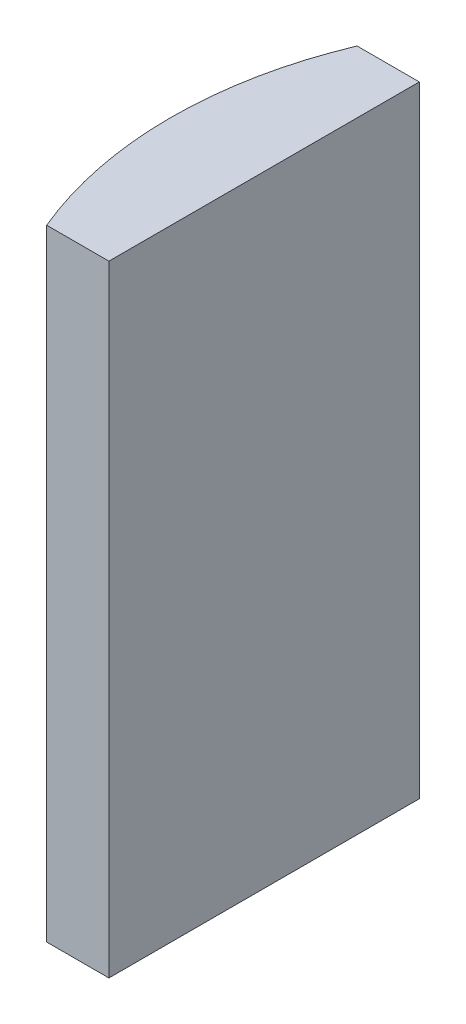
from build123d import *

# Parameters (mm, degrees)
EXTRUDE_1_DEPTH = 20


with BuildPart() as part:
    # 草图1 → 凸台-拉伸1 (new body)
    with BuildSketch(Plane(origin=(0, 0, 0), x_dir=(1, 0, 0), z_dir=(0, 1, 0))):
        with BuildLine():
            Line((-7.568926661, 5), (-5.564795665, 5))
            Line((-5.564795665, 5), (-5.564795665, -5))
            Line((-5.564795665, -5), (-7.568926661, -5))
            ThreePointArc((-7.568926661, -5), (-8.574795665, 0), (-7.568926661, 5))
        make_face()
    extrude(amount=EXTRUDE_1_DEPTH)


solid = part.part
